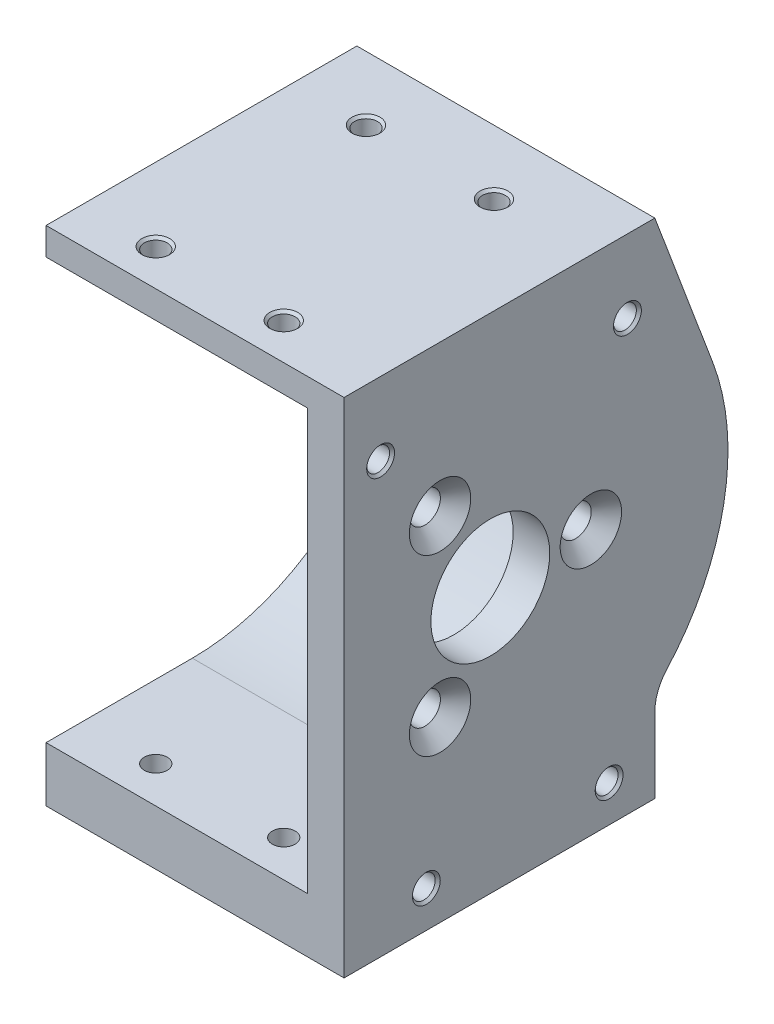
from build123d import *

# Parameters (mm, degrees)
MOTOR_SHELL_DEPTH               = 32.6
MOTOR_MOUNT_DEPTH               = 4
MOUNTING_HOLE_D                 = 3.4
MOUNTING_HOLE_CSINK_D           = 6.72
MOUNTING_HOLE_CSINK_ANGLE       = 90
HOLE_DUPLICATION_COUNT          = 3
SKETCH11_R                      = 6.5
SHAFT_BASE_CUTOUT_DEPTH         = 33.6
M3X0_5_TAPPED_HOLE1_D           = 2.5
M3X0_5_TAPPED_HOLE1_DEPTH       = 5
M3X0_5_TAPPED_HOLE1_CSINK_D     = 3.05
M3X0_5_TAPPED_HOLE1_CSINK_ANGLE = 90
M3X0_5_TAPPED_HOLE1_TIP         = 0.751075774
M3X0_5_TAPPED_HOLE2_D           = 2.5
M3X0_5_TAPPED_HOLE2_CSINK_D     = 3.05
M3X0_5_TAPPED_HOLE2_CSINK_ANGLE = 90
M3X0_5_TAPPED_HOLE3_D           = 2.5
M3X0_5_TAPPED_HOLE3_DEPTH       = 5
M3X0_5_TAPPED_HOLE3_TIP         = 0.751075774
TAP_DRILL_FOR_M3X0_5_TAP2_D     = 2.5
TAP_DRILL_FOR_M3X0_5_TAP2_DEPTH = 15
TAP_DRILL_FOR_M3X0_5_TAP2_TIP   = 0.751075774
CUT_EXTRUDE1_DEPTH              = 28.6


with BuildPart() as part:
    # Motor Shell Profile → Motor Shell (new body)
    with BuildSketch(Plane(origin=(0, 0, 0), x_dir=(0, 0, -1), z_dir=(1, 0, 0))):
        with BuildLine():
            Line((0, 22), (-16, 22))
            Line((-16, 22), (-16, 26))
            Line((-16, 26), (18, 26))
            Line((18, 26), (24.336, 9.152))
            ThreePointArc((24.336, 9.152), (25.543974558, -4.848233058), (19.290322581, -17.432253289))
            ThreePointArc((19.290322581, -17.432253289), (18.333717374, -18.988556671), (18, -20.784609691))
            Line((18, -20.784609691), (18, -29))
            Line((18, -29), (-16, -29))
            Line((-16, -29), (-16, -22))
            Line((-16, -22), (0, -22))
            ThreePointArc((0, -22), (22, 0), (0, 22))
        make_face()
    extrude(amount=MOTOR_SHELL_DEPTH)

    # Sketch3 → Motor Mount (add)
    with BuildSketch(Plane(origin=(28.6, 0, 0), x_dir=(0, 0, -1), z_dir=(1, 0, 0))):
        with BuildLine():
            Line((0, 22), (-16, 22))
            Line((-16, 22), (-16, -22))
            Line((-16, -22), (0, -22))
            ThreePointArc((0, -22), (22, 0), (0, 22))
        make_face()
    extrude(amount=MOTOR_MOUNT_DEPTH)

    # Mounting Hole (through all)
    with Locations(Plane(origin=(32.6, 0, 0), x_dir=(0, 0, -1), z_dir=(1, 0, 0))):
        with Locations((11, 0)):
            mounting_hole = CounterSinkHole(MOUNTING_HOLE_D / 2, MOUNTING_HOLE_CSINK_D / 2, counter_sink_angle=MOUNTING_HOLE_CSINK_ANGLE)

    # Hole Duplication: Mounting Hole ×3 about axis
    hole_duplication_axis = Axis((0, 0, 0), (1, 0, 0))
    for i in range(1, HOLE_DUPLICATION_COUNT):
        add(mounting_hole.rotate(hole_duplication_axis, i * 360 / HOLE_DUPLICATION_COUNT), mode=Mode.SUBTRACT)

    # Sketch11 → Shaft Base Cutout (cut, through all)
    with BuildSketch(Plane(origin=(32.6, 0, 0), x_dir=(0, 0, -1), z_dir=(1, 0, 0))):
        Circle(SKETCH11_R)
    extrude(amount=-SHAFT_BASE_CUTOUT_DEPTH, mode=Mode.SUBTRACT)

    # M3x0.5 Tapped Hole1
    with Locations(Plane(origin=(32.6, 0, 0), x_dir=(0, 0, -1), z_dir=(1, 0, 0))):
        with Locations((-7, -25), (13, -25), (-12, 18), (15, 18)):
            CounterSinkHole(M3X0_5_TAPPED_HOLE1_D / 2, M3X0_5_TAPPED_HOLE1_CSINK_D / 2, depth=M3X0_5_TAPPED_HOLE1_DEPTH, counter_sink_angle=M3X0_5_TAPPED_HOLE1_CSINK_ANGLE)
            with Locations((0, 0, -(M3X0_5_TAPPED_HOLE1_DEPTH + M3X0_5_TAPPED_HOLE1_TIP / 2))):  # 118° drill point
                Cone(0, M3X0_5_TAPPED_HOLE1_D / 2, M3X0_5_TAPPED_HOLE1_TIP, mode=Mode.SUBTRACT)

    # M3x0.5 Tapped Hole2 (through all)
    with Locations(Plane(origin=(0, 26, 0), x_dir=(1, 0, 0), z_dir=(0, 1, 0))):
        with Locations((22, -12), (8, -12), (8, 11), (22, 11)):
            CounterSinkHole(M3X0_5_TAPPED_HOLE2_D / 2, M3X0_5_TAPPED_HOLE2_CSINK_D / 2, counter_sink_angle=M3X0_5_TAPPED_HOLE2_CSINK_ANGLE)

    # M3x0.5 Tapped Hole3
    with Locations(Plane(origin=(0, 0, -18), x_dir=(-1, 0, 0), z_dir=(0, 0, -1))):
        with Locations((-24, -24.2)):
            Hole(M3X0_5_TAPPED_HOLE3_D / 2, depth=M3X0_5_TAPPED_HOLE3_DEPTH)
            with Locations((0, 0, -(M3X0_5_TAPPED_HOLE3_DEPTH + M3X0_5_TAPPED_HOLE3_TIP / 2))):  # 118° drill point
                Cone(0, M3X0_5_TAPPED_HOLE3_D / 2, M3X0_5_TAPPED_HOLE3_TIP, mode=Mode.SUBTRACT)

    # Tap Drill for M3x0.5 Tap2
    with Locations(Plane(origin=(0, 0, -25), x_dir=(1, 0, 0), z_dir=(0, 0, -1))):
        with Locations((14, -21.5)):
            Hole(TAP_DRILL_FOR_M3X0_5_TAP2_D / 2, depth=TAP_DRILL_FOR_M3X0_5_TAP2_DEPTH)
            with Locations((0, 0, -(TAP_DRILL_FOR_M3X0_5_TAP2_DEPTH + TAP_DRILL_FOR_M3X0_5_TAP2_TIP / 2))):  # 118° drill point
                Cone(0, TAP_DRILL_FOR_M3X0_5_TAP2_D / 2, TAP_DRILL_FOR_M3X0_5_TAP2_TIP, mode=Mode.SUBTRACT)

    # Sketch25 → Cut-Extrude1 (cut)
    with BuildSketch(Plane.ZY):
        with BuildLine():
            Line((0, 23), (16, 23))
            Line((16, 23), (16, -23))
            Line((16, -23), (0, -23))
            ThreePointArc((0, -23), (-23, 0), (0, 23))
        make_face()
    extrude(amount=-CUT_EXTRUDE1_DEPTH, mode=Mode.SUBTRACT)


solid = part.part
